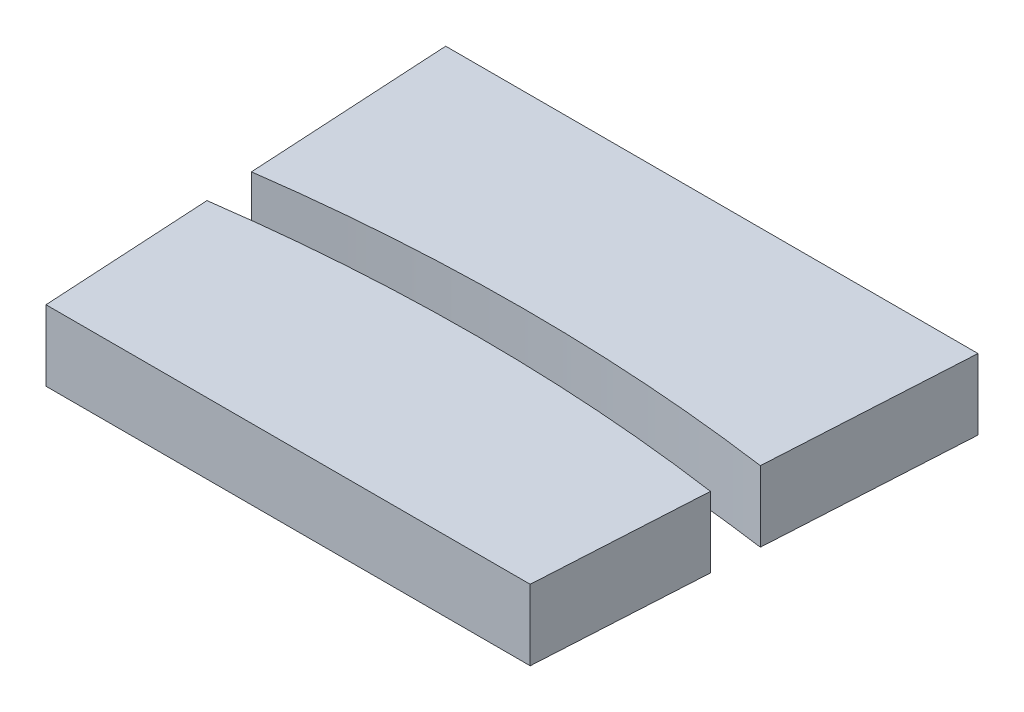
from build123d import *

# Parameters (mm, degrees)
BOSS_EXTRUDE1_DEPTH      = 3
CUT_EXTRUDE10_DEPTH      = 1
CUT_EXTRUDE10_DEPTH_BACK = 4
CUT_EXTRUDE11_DEPTH      = 1
CUT_EXTRUDE11_DEPTH_BACK = 4


with BuildPart() as part:
    # Sketch1 → Boss-Extrude1 (new body)
    with BuildSketch(Plane(origin=(0, 0, 0), x_dir=(1, 0, 0), z_dir=(0, 1, 0))):
        Polygon((-11.589955224, 91.5), (-10, 63.5), (0, 63.5), (0, 91.5), align=None)
    extrude(amount=BOSS_EXTRUDE1_DEPTH)

    # Sketch55 → Cut-Extrude10 (cut, two sides)
    with BuildSketch(Plane(origin=(0, 3, 0), x_dir=(1, 0, 0), z_dir=(0, 1, 0))) as cut_extrude10_sk:
        Polygon((-10.283920576, 68.5), (0, 68.5), (0, 63.5), (-10, 63.5), align=None)
        Polygon((-11.306034648, 86.5), (-11.589955224, 91.5), (0, 91.5), (0, 86.5), align=None)
    extrude(amount=CUT_EXTRUDE10_DEPTH, mode=Mode.SUBTRACT)
    extrude(cut_extrude10_sk.sketch, amount=-CUT_EXTRUDE10_DEPTH_BACK, mode=Mode.SUBTRACT)

    # Mirror14: part across plane


with BuildPart() as part_1:
    add(part.part)
    add(part.part.mirror(Plane(origin=(0, 0, 0), x_dir=(0, 0, 1), z_dir=(1, 0, 0))))

    # Sketch56 → Cut-Extrude11 (cut, two sides)
    with BuildSketch(Plane(origin=(0, 3, 0), x_dir=(1, 0, 0), z_dir=(0, 1, 0))) as cut_extrude11_sk:
        with BuildLine():
            Line((-10.829714823, 77.74938763), (-10.695527892, 75.74863486))
            ThreePointArc((-10.695527892, 75.74863486), (0, 76.5), (10.695527892, 75.74863486))
            Line((10.695527892, 75.74863486), (10.809300181, 77.752228454))
            ThreePointArc((10.809300181, 77.752228454), (-0.010305677, 78.499999324), (-10.829714823, 77.74938763))
        make_face()
    extrude(amount=CUT_EXTRUDE11_DEPTH, mode=Mode.SUBTRACT)
    extrude(cut_extrude11_sk.sketch, amount=-CUT_EXTRUDE11_DEPTH_BACK, mode=Mode.SUBTRACT)


solid = part_1.part
